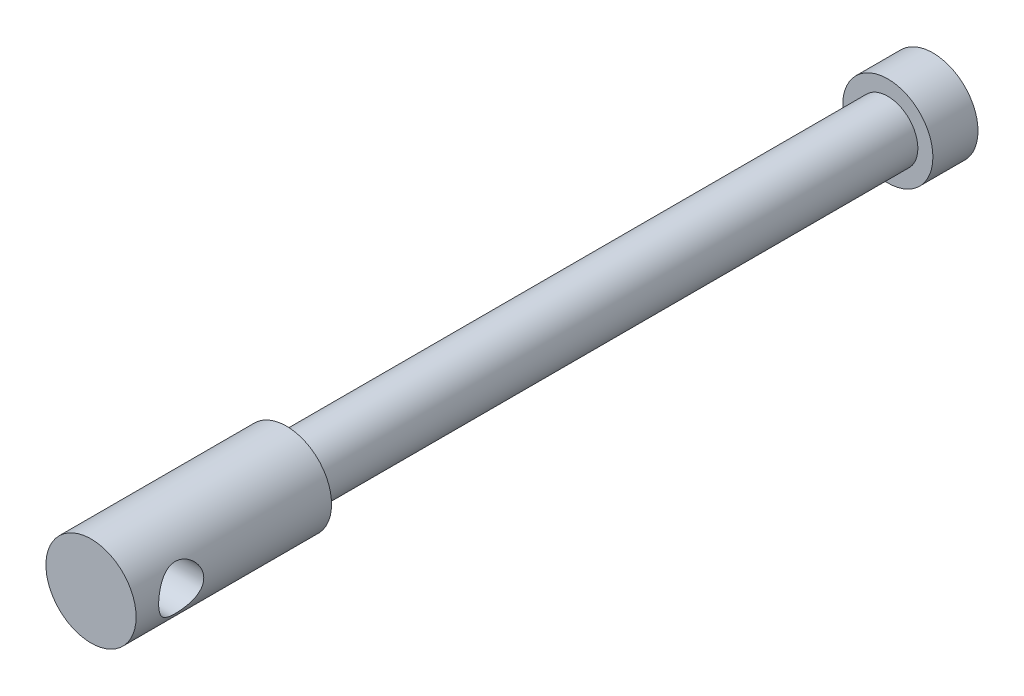
from build123d import *

# Parameters (mm, degrees)
SKETCH_2_R               = 1.5
CUT_EXTRUDE_1_DEPTH      = 4
CUT_EXTRUDE_1_DEPTH_BACK = 4


with BuildPart() as part:
    # 草圖1 → 旋轉1 (revolve)
    with BuildSketch(Plane(origin=(0, 0, 0), x_dir=(0, 0, -1), z_dir=(1, 0, 0))):
        Polygon((0, 2), (0, 3), (-13, 3), (-13, 0), (43, 0), (43, 3), (40, 3), (40, 2), align=None)
    revolve(axis=Axis((0, 0, 17.804347826), (0, 0, -1)))

    # 草圖2 → 除料-伸長1 (cut, two sides)
    with BuildSketch(Plane(origin=(0, 0, 0), x_dir=(0, 0, -1), z_dir=(1, 0, 0))) as cut_extrude_1_sk:
        with Locations((-10, 0)):
            Circle(SKETCH_2_R)
    extrude(amount=CUT_EXTRUDE_1_DEPTH, mode=Mode.SUBTRACT)
    extrude(cut_extrude_1_sk.sketch, amount=-CUT_EXTRUDE_1_DEPTH_BACK, mode=Mode.SUBTRACT)


solid = part.part
